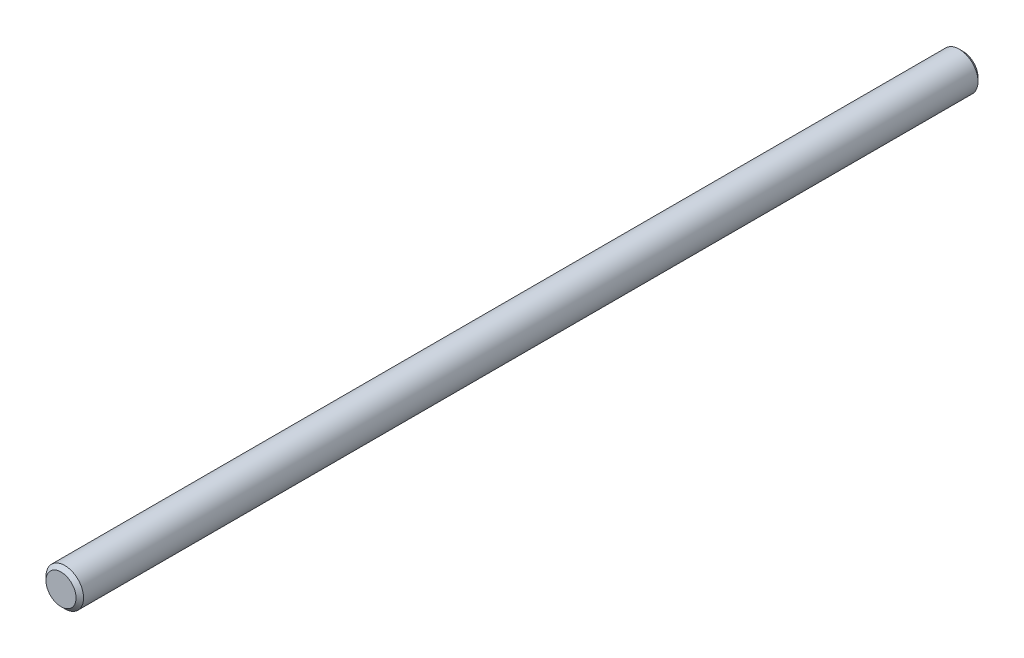
from build123d import *

# Parameters (mm, degrees)
SKETCH1_R      = 1.5875
EXTRUDE1_DEPTH = 38.1
CHAMFER1_SIZE  = 0.3175


with BuildPart() as part:
    # Sketch1 → Extrude1 (new body, symmetric)
    with BuildSketch(Plane.XY):
        Circle(SKETCH1_R)
    extrude(amount=EXTRUDE1_DEPTH, both=True)

    # Chamfer1
    chamfer1_edges = [part.edges().sort_by_distance(p)[0] for p in [
        (-1.5875, 0, -38.1),
        (-1.5875, 0, 38.1),
    ]]
    chamfer(chamfer1_edges, length=CHAMFER1_SIZE)


solid = part.part
